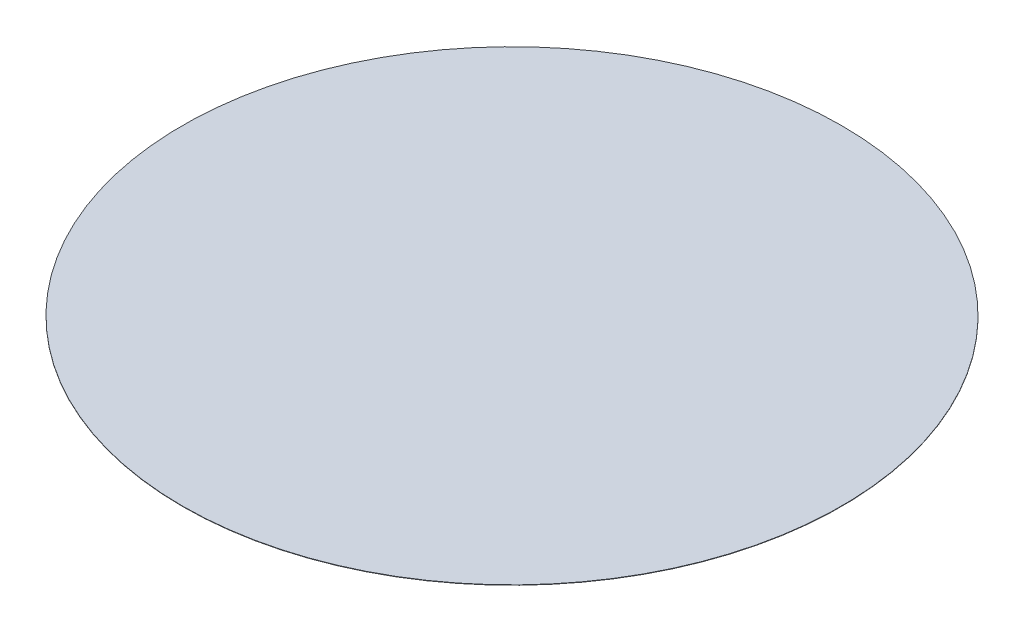
from build123d import *

# Parameters (mm, degrees)
SKETCH1_R           = 22.5
BOSS_EXTRUDE1_DEPTH = 0.0254


with BuildPart() as part:
    # Sketch1 → Boss-Extrude1 (new body)
    with BuildSketch(Plane(origin=(0, 0, 0), x_dir=(1, 0, 0), z_dir=(0, 1, 0))):
        Circle(SKETCH1_R)
    extrude(amount=BOSS_EXTRUDE1_DEPTH)


solid = part.part
